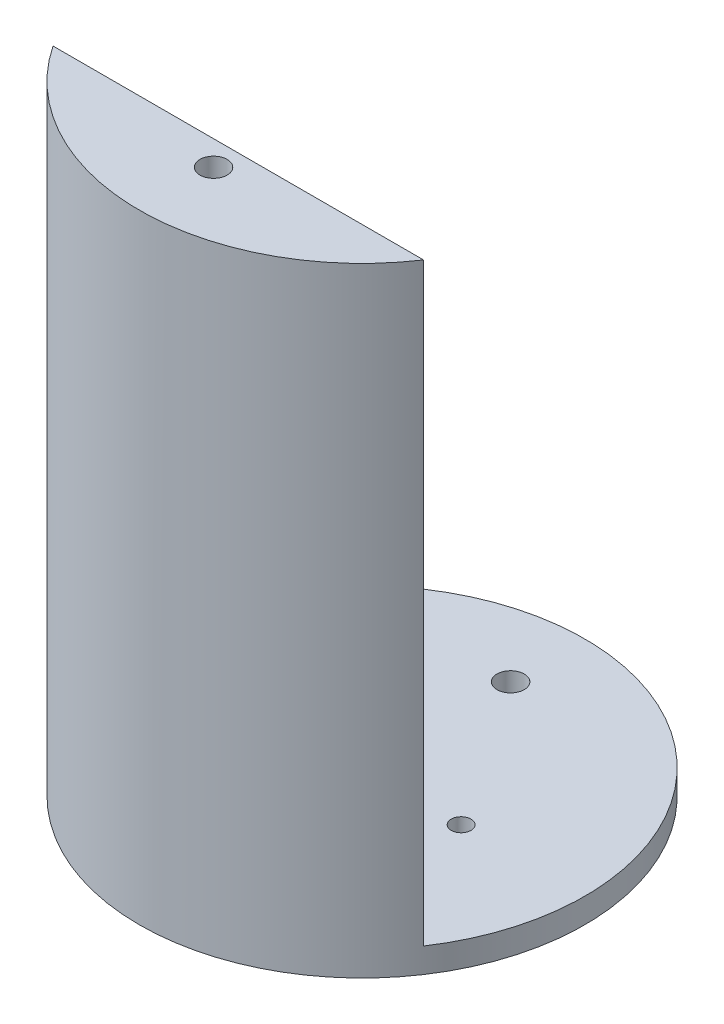
from build123d import *

# Parameters (mm, degrees)
SKETCH1_R                  = 57.15
SKETCH1_R_2                = 6.35
SKETCH1_R_3                = 3.4925
BOSS_EXTRUDE1_DEPTH        = 6.35
F_8_0_199_DIAMETER_HOLE1_D = 5.0546
SKETCH6_R                  = 3.4925
BOSS_EXTRUDE3_DEPTH        = 152.4


with BuildPart() as part:
    # Sketch1 → Boss-Extrude1 (new body)
    with BuildSketch(Plane(origin=(0, 0, 0), x_dir=(1, 0, 0), z_dir=(0, 1, 0))):
        Circle(SKETCH1_R)
        Circle(SKETCH1_R_2, mode=Mode.SUBTRACT)
        with Locations((0, 38.1)):
            Circle(SKETCH1_R_3, mode=Mode.SUBTRACT)
        with Locations((0, -38.1)):
            Circle(SKETCH1_R_3, mode=Mode.SUBTRACT)
    extrude(amount=BOSS_EXTRUDE1_DEPTH)

    # #8 (0.199) Diameter Hole1 (through all)
    with Locations(Plane(origin=(-25.4, 6.35, 0), x_dir=(0, 0, 1), z_dir=(0, 1, 0))):
        with Locations((0, 0), (0, 50.8)):
            Hole(F_8_0_199_DIAMETER_HOLE1_D / 2)

    # Sketch6 → Boss-Extrude3 (add)
    with BuildSketch(Plane(origin=(0, 6.35, 0), x_dir=(1, 0, 0), z_dir=(0, 1, 0))):
        with BuildLine():
            Line((47.519048812, -31.75), (-47.519048812, -31.75))
            ThreePointArc((-47.519048812, -31.75), (0, -57.15), (47.519048812, -31.75))
        make_face()
        with Locations((0, -38.1)):
            Circle(SKETCH6_R, mode=Mode.SUBTRACT)
    extrude(amount=BOSS_EXTRUDE3_DEPTH)


solid = part.part
